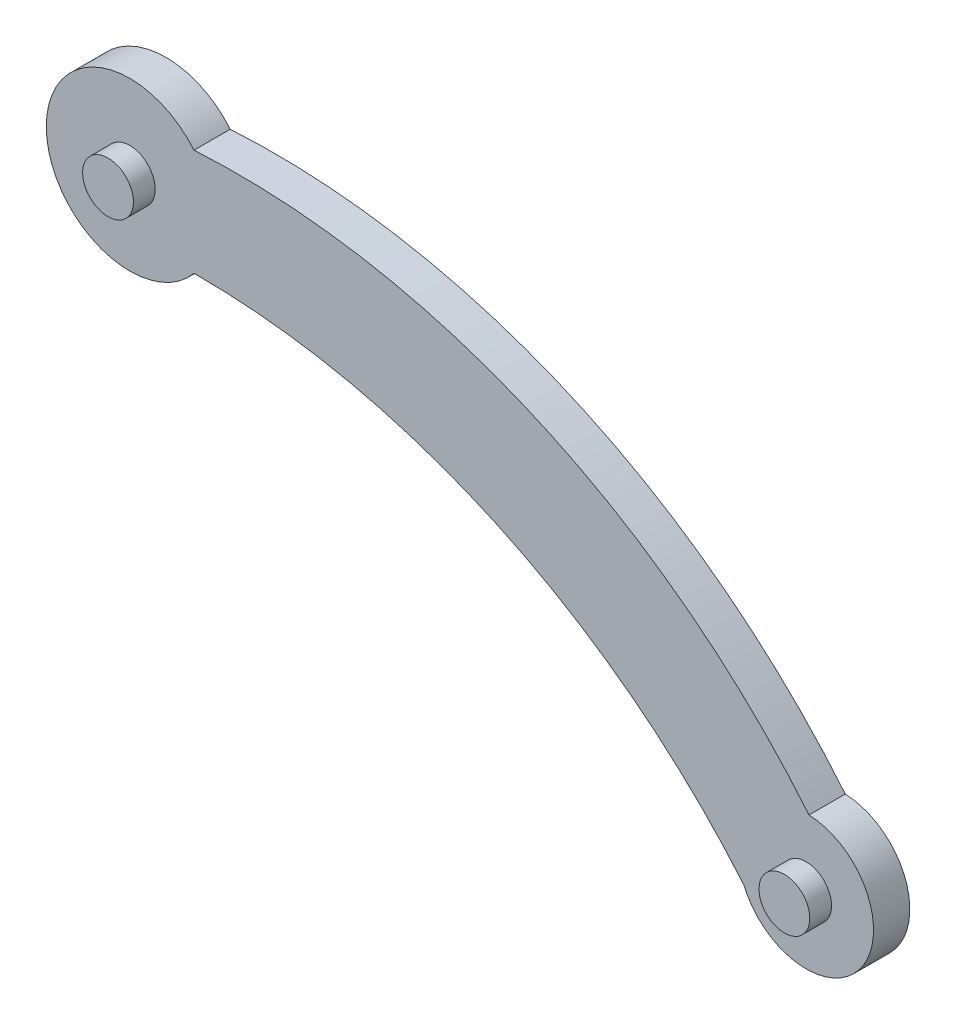
from build123d import *

# Parameters (mm, degrees)
BOSS_EXTRUDE1_DEPTH = 10
SKETCH2_R           = 7
BOSS_EXTRUDE2_DEPTH = 6


with BuildPart() as part:
    # Sketch1 → Boss-Extrude1 (new body)
    with BuildSketch(Plane.XY):
        with BuildLine():
            ThreePointArc((-43.08998785, 39.062645298), (50.557727896, 22.443015988), (126.455624698, -34.877277135))
            ThreePointArc((126.455624698, -34.877277135), (140.904450524, -64.085787948), (108.507084419, -60.576323444))
            ThreePointArc((108.507084419, -60.576323444), (40.525240485, -8.589143953), (-43.08998785, 9.650689563))
            ThreePointArc((-43.08998785, 9.650689563), (-83.811407941, 24.356667431), (-43.08998785, 39.062645298))
        make_face()
    extrude(amount=BOSS_EXTRUDE1_DEPTH)

    # Sketch2 → Boss-Extrude2 (add)
    with BuildSketch(Plane.XY.offset(10)):
        with Locations((125.668384571, -53.444726012)):
            Circle(SKETCH2_R)
        with Locations((-60.795267601, 24.356667431)):
            Circle(SKETCH2_R)
    extrude(amount=BOSS_EXTRUDE2_DEPTH)


solid = part.part
